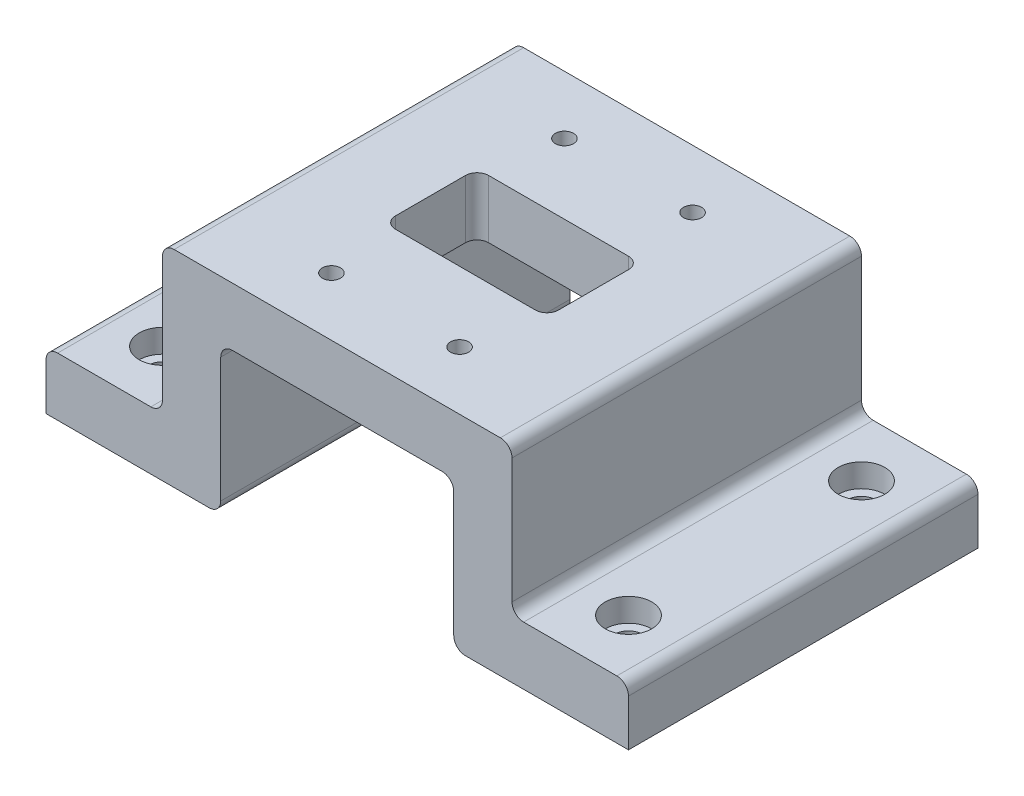
from build123d import *

# Parameters (mm, degrees)
SKETCH2_W                        = 60
SKETCH2_H                        = 60
BOSS_EXTRUDE1_DEPTH              = 10
SKETCH7_W                        = 28
SKETCH7_H                        = 16
CUT_EXTRUDE2_DEPTH               = 44.588989435
FILLET2_R                        = 2
CBORE_FOR_M2_5_SHCS2_D           = 3.1
CBORE_FOR_M2_5_SHCS2_CBORE_D     = 5.5
CBORE_FOR_M2_5_SHCS2_CBORE_DEPTH = 2.5
MOVE_FACE1_BY                    = 3.5
MOVE_FACE1_2_BY                  = 3.5
MOVE_FACE1_3_BY                  = 3.5
MOVE_FACE1_4_BY                  = 3.5
SKETCH11_W                       = 10
SKETCH11_H                       = 25.4
BOSS_EXTRUDE2_DEPTH              = 60
SKETCH12_W                       = 20
SKETCH12_H                       = 60
BOSS_EXTRUDE3_DEPTH              = 10
CBORE_FOR_M4_SHCS1_D             = 4.8
CBORE_FOR_M4_SHCS1_CBORE_D       = 8
CBORE_FOR_M4_SHCS1_CBORE_DEPTH   = 4
FILLET5_R                        = 2


with BuildPart() as part:
    # Sketch2 → Boss-Extrude1 (new body)
    with BuildSketch(Plane(origin=(0, 0, 0), x_dir=(1, 0, 0), z_dir=(0, 1, 0))):
        Rectangle(SKETCH2_W, SKETCH2_H)
    extrude(amount=BOSS_EXTRUDE1_DEPTH)

    # Sketch7 → Cut-Extrude2 (cut, through all)
    with BuildSketch(Plane(origin=(0, 10, 0), x_dir=(1, 0, 0), z_dir=(0, 1, 0))):
        Rectangle(SKETCH7_W, SKETCH7_H)
    extrude(amount=-CUT_EXTRUDE2_DEPTH, mode=Mode.SUBTRACT)

    # Fillet2
    fillet2_edges = [part.edges().sort_by_distance(p)[0] for p in [
        (-14, 5, 8),
        (-14, 5, -8),
        (14, 5, -8),
        (14, 5, 8),
    ]]
    fillet(fillet2_edges, radius=FILLET2_R)

    # CBORE for M2.5 SHCS2 (through all)
    with Locations(Plane(origin=(0, 0, 0), x_dir=(-1, 0, 0), z_dir=(0, -1, 0))):
        with Locations((11, -20), (-11, -20), (11, 20), (-11, 20)):
            CounterBoreHole(CBORE_FOR_M2_5_SHCS2_D / 2, CBORE_FOR_M2_5_SHCS2_CBORE_D / 2, CBORE_FOR_M2_5_SHCS2_CBORE_DEPTH)

    # Move Face1: a face moved inward by 3.5
    extrude(part.faces().sort_by_distance((11, 2.5, -17.8))[0], amount=MOVE_FACE1_BY, dir=(0, 1, 0), mode=Mode.SUBTRACT)

    # Move Face1 2: a face moved inward by 3.5
    extrude(part.faces().sort_by_distance((-11, 2.5, -17.8))[0], amount=MOVE_FACE1_2_BY, dir=(0, 1, 0), mode=Mode.SUBTRACT)

    # Move Face1 3: a face moved inward by 3.5
    extrude(part.faces().sort_by_distance((11, 2.5, 22.2))[0], amount=MOVE_FACE1_3_BY, dir=(0, 1, 0), mode=Mode.SUBTRACT)

    # Move Face1 4: a face moved inward by 3.5
    extrude(part.faces().sort_by_distance((-11, 2.5, 22.2))[0], amount=MOVE_FACE1_4_BY, dir=(0, 1, 0), mode=Mode.SUBTRACT)

    # Sketch11 → Boss-Extrude2 (add)
    with BuildSketch(Plane(origin=(0, 0, -30), x_dir=(-1, 0, 0), z_dir=(0, 0, -1))):
        with Locations((-25, -12.7)):
            Rectangle(SKETCH11_W, SKETCH11_H)
    boss_extrude2 = extrude(amount=-BOSS_EXTRUDE2_DEPTH)

    # Sketch12 → Boss-Extrude3 (add)
    with BuildSketch(Plane.XZ.offset(25.4)):
        with Locations((40, 0)):
            Rectangle(SKETCH12_W, SKETCH12_H)
    boss_extrude3 = extrude(amount=-BOSS_EXTRUDE3_DEPTH)

    # CBORE for M4 SHCS1 (through all)
    with Locations(Plane(origin=(0, -15.4, 0), x_dir=(1, 0, 0), z_dir=(0, 1, 0))):
        with Locations((40, 20), (40, -20)):
            cbore_for_m4_shcs1 = CounterBoreHole(CBORE_FOR_M4_SHCS1_D / 2, CBORE_FOR_M4_SHCS1_CBORE_D / 2, CBORE_FOR_M4_SHCS1_CBORE_DEPTH)

    # Mirror1: Boss-Extrude2, Boss-Extrude3, CBORE for M4 SHCS1 across plane
    add(boss_extrude2.mirror(Plane(origin=(0, 0, 0), x_dir=(0, 0, 1), z_dir=(1, 0, 0))))
    add(boss_extrude3.mirror(Plane(origin=(0, 0, 0), x_dir=(0, 0, 1), z_dir=(1, 0, 0))))
    add(cbore_for_m4_shcs1.mirror(Plane(origin=(0, 0, 0), x_dir=(0, 0, 1), z_dir=(1, 0, 0))), mode=Mode.SUBTRACT)

    # Fillet5
    fillet5_edges = [part.edges().sort_by_distance(p)[0] for p in [
        (50, -15.4, 0),
        (30, -15.4, 0),
        (30, 10, 0),
        (-20, 0, 0),
        (-20, -25.4, 0),
        (-30, -15.4, 0),
        (-50, -15.4, 0),
        (-30, 10, 0),
        (20, 0, 0),
        (20, -25.4, 0),
    ]]
    fillet(fillet5_edges, radius=FILLET5_R)


solid = part.part
